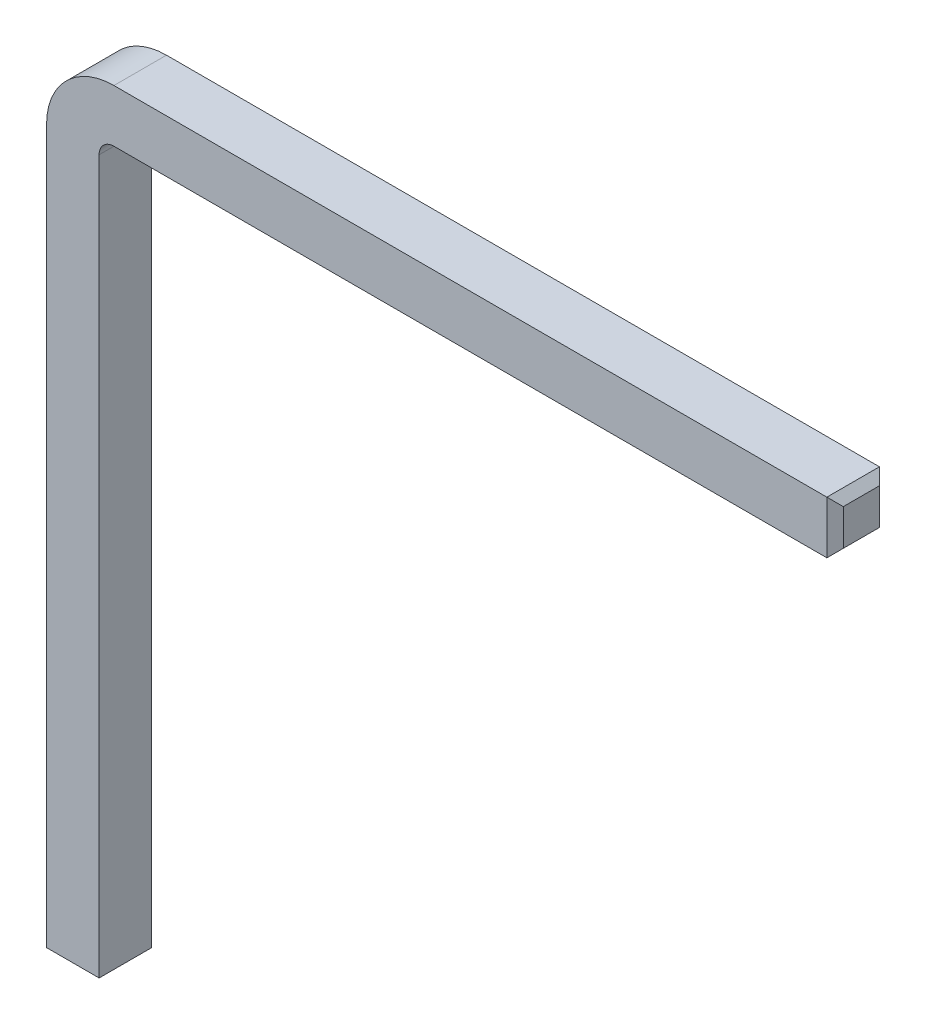
from build123d import *

# Parameters (mm, degrees)
SKETCH_1_W     = 0.64
SKETCH_1_H     = 0.64
CHAMFER_1_SIZE = 0.1


with BuildPart() as part:
    # По траектории1: sweep along a path in Эскиз2
    with BuildLine(Plane.XY) as sweep_1_path:
        Line((0, 0), (0, 8.78))
        ThreePointArc((0, 8.78), (0.146446609, 9.133553391), (0.5, 9.28))
        Line((0.5, 9.28), (9.28, 9.28))
    # Эскиз1 → По траектории1 (sweep)
    with BuildSketch(Plane(origin=(0, 0, 0), x_dir=(1, 0, 0), z_dir=(0, 1, 0))):
        Rectangle(SKETCH_1_W, SKETCH_1_H)
    sweep(path=sweep_1_path.line)

    # Фаска1
    chamfer_1_edges = [part.edges().sort_by_distance(p)[0] for p in [
        (9.28, 8.96, 0),
        (9.28, 9.28, 0.32),
        (9.28, 9.6, 0),
        (9.28, 9.28, -0.32),
        (0, 0, 0.32),
        (-0.32, 0, 0),
        (0, 0, -0.32),
        (0.32, 0, 0),
    ]]
    chamfer(chamfer_1_edges, length=CHAMFER_1_SIZE)


solid = part.part
